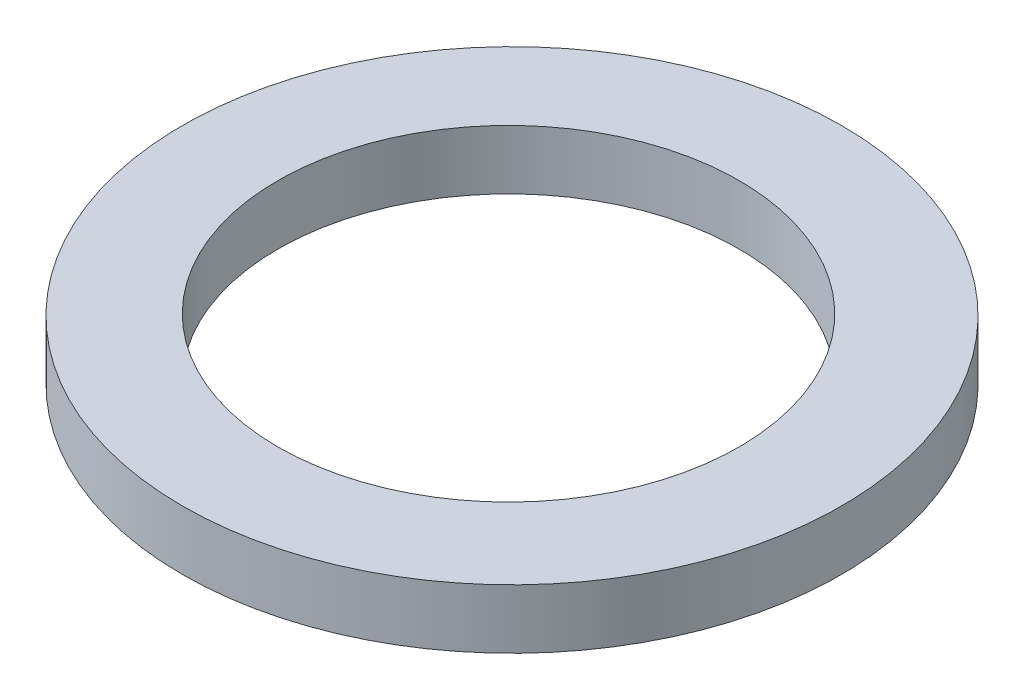
from build123d import *

# Parameters (mm, degrees)
SKETCH1_R           = 25.4
SKETCH1_R_2         = 17.78
BOSS_EXTRUDE1_DEPTH = 4.572


with BuildPart() as part:
    # Sketch1 → Boss-Extrude1 (new body)
    with BuildSketch(Plane(origin=(0, 0, 0), x_dir=(1, 0, 0), z_dir=(0, 1, 0))):
        with Locations((0.268183518, 0)):
            Circle(SKETCH1_R)
        Circle(SKETCH1_R_2, mode=Mode.SUBTRACT)
    extrude(amount=BOSS_EXTRUDE1_DEPTH)


solid = part.part
